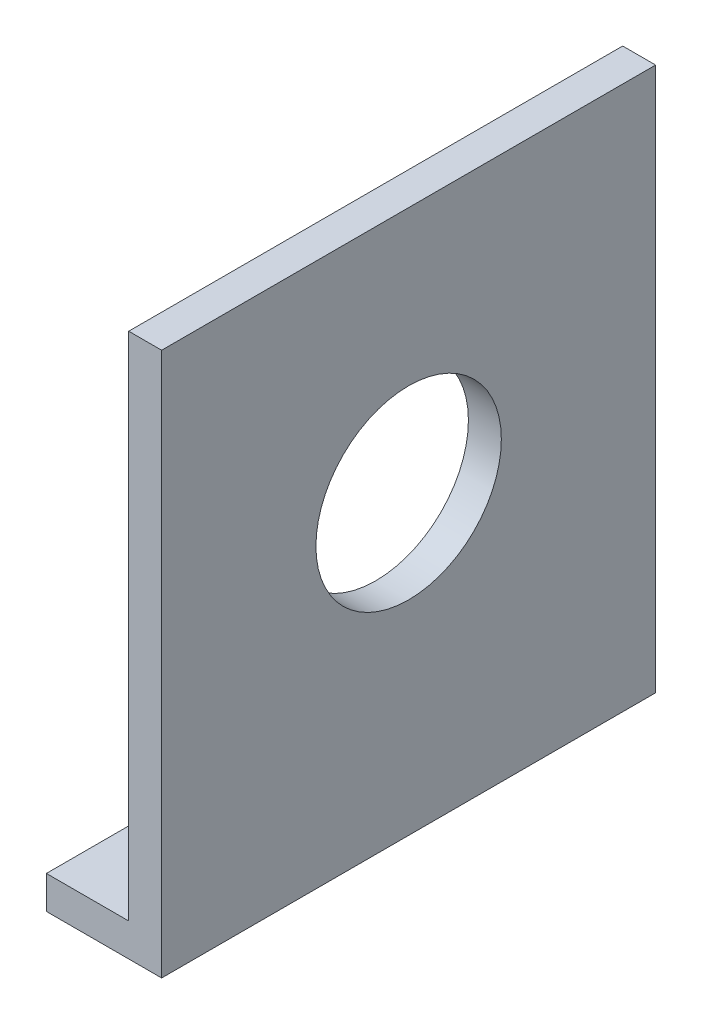
from build123d import *

# Parameters (mm, degrees)
SKETCH3_W           = 38.1
SKETCH3_H           = 41.932660102
SKETCH3_R           = 7.1501
BOSS_EXTRUDE1_DEPTH = 2.54
SKETCH4_W           = 8.89
SKETCH4_H           = 2.54
BOSS_EXTRUDE2_DEPTH = 8.89


with BuildPart() as part:
    # Sketch3 → Boss-Extrude1 (new body)
    with BuildSketch(Plane(origin=(-73.0954, 0, 0), x_dir=(0, 0, -1), z_dir=(1, 0, 0))):
        with Locations((0, -1.916330051)):
            Rectangle(SKETCH3_W, SKETCH3_H)
        Circle(SKETCH3_R, mode=Mode.SUBTRACT)
    extrude(amount=-BOSS_EXTRUDE1_DEPTH)

    # Sketch4 → Boss-Extrude2 (add)
    with BuildSketch(Plane(origin=(-73.0954, 0, 0), x_dir=(0, 0, -1), z_dir=(1, 0, 0))):
        with Locations((14.605, -21.612660102)):
            Rectangle(SKETCH4_W, SKETCH4_H)
        with Locations((-14.605, -21.612660102)):
            Rectangle(SKETCH4_W, SKETCH4_H)
    extrude(amount=-BOSS_EXTRUDE2_DEPTH)


solid = part.part
